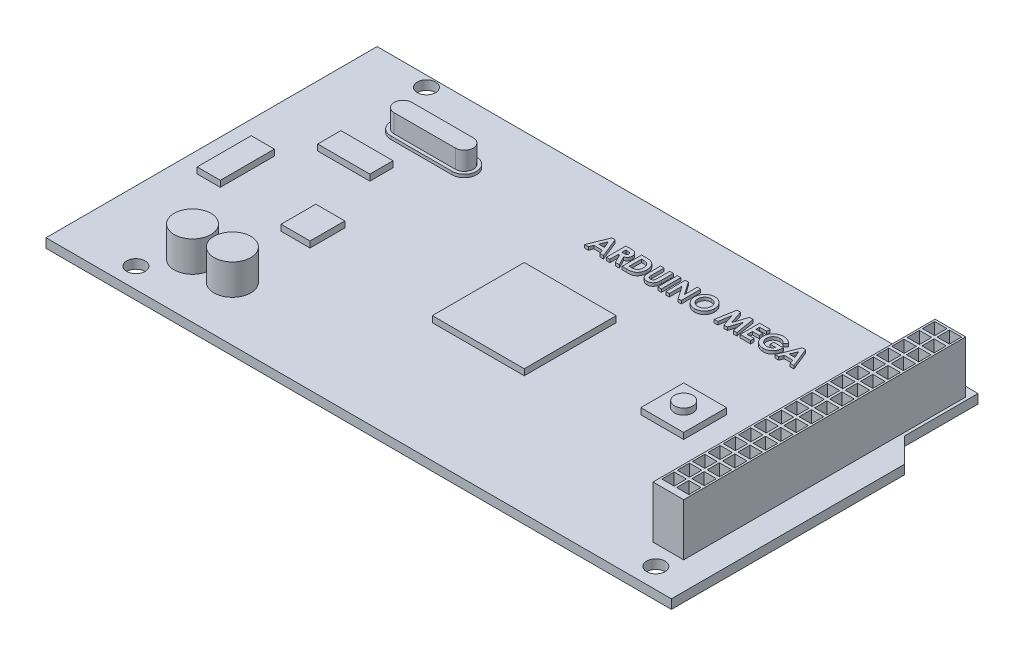
from build123d import *

# Parameters (mm, degrees)
SKETCH1_W            = 102
SKETCH1_H            = 54
BOSS_EXTRUDE1_DEPTH  = 1.5
CUT_EXTRUDE1_DEPTH   = 1.5
SKETCH3_W            = 5
SKETCH3_H            = 46
BOSS_EXTRUDE2_DEPTH  = 8.5
SKETCH4_W            = 2
SKETCH4_H            = 2
CUT_EXTRUDE2_DEPTH   = 5
SKETCH5_W            = 15
SKETCH5_H            = 15
BOSS_EXTRUDE3_DEPTH  = 1
SKETCH6_R            = 3
BOSS_EXTRUDE4_DEPTH  = 5
BOSS_EXTRUDE5_DEPTH  = 0.5
SKETCH8_W            = 8.498910204
SKETCH8_H            = 3.777293425
BOSS_EXTRUDE6_DEPTH  = 1
SKETCH9_W            = 4.72161678
SKETCH9_H            = 5.665940136
BOSS_EXTRUDE7_DEPTH  = 1
SKETCH10_R           = 1.5
CUT_EXTRUDE3_DEPTH   = 11
SKETCH11_R           = 1.5
CUT_EXTRUDE4_DEPTH   = 11
SKETCH12_R           = 1.5
CUT_EXTRUDE5_DEPTH   = 11
SKETCH13_R           = 1.5
CUT_EXTRUDE6_DEPTH   = 11
SKETCH14_W           = 7
SKETCH14_H           = 7
BOSS_EXTRUDE8_DEPTH  = 1
SKETCH15_R           = 1.5
BOSS_EXTRUDE9_DEPTH  = 1
SKETCH16_W           = 3.779662731
SKETCH16_H           = 8.81921304
BOSS_EXTRUDE10_DEPTH = 1
SKETCH17_W           = 0.569871795
SKETCH17_H           = 3.175
BOSS_EXTRUDE11_DEPTH = 0.5
BOSS_EXTRUDE12_DEPTH = 3


with BuildPart() as part:
    # Sketch1 → Boss-Extrude1 (new body)
    with BuildSketch(Plane(origin=(0, 0, 0), x_dir=(1, 0, 0), z_dir=(0, 1, 0))):
        Rectangle(SKETCH1_W, SKETCH1_H)
    extrude(amount=BOSS_EXTRUDE1_DEPTH)

    # Sketch2 → Cut-Extrude1 (cut)
    with BuildSketch(Plane(origin=(0, 1.5, 0), x_dir=(1, 0, 0), z_dir=(0, 1, 0))):
        Polygon((47, 27), (47, 15), (51, 11), (51, 27), align=None)
    extrude(amount=-CUT_EXTRUDE1_DEPTH, mode=Mode.SUBTRACT)

    # Sketch3 → Boss-Extrude2 (add)
    with BuildSketch(Plane(origin=(0, 1.5, 0), x_dir=(1, 0, 0), z_dir=(0, 1, 0))):
        with Locations((44, 2.5)):
            Rectangle(SKETCH3_W, SKETCH3_H)
    extrude(amount=BOSS_EXTRUDE2_DEPTH)

    # Sketch4 → Cut-Extrude2 (cut)
    with BuildSketch(Plane(origin=(0, 10, 0), x_dir=(1, 0, 0), z_dir=(0, 1, 0))):
        with Locations((45.197057876, 24.138037012)):
            Rectangle(SKETCH4_W, SKETCH4_H)
        with Locations((42.802942124, 24.138037012)):
            Rectangle(SKETCH4_W, SKETCH4_H)
        with Locations((42.802942124, 21.638037012)):
            Rectangle(SKETCH4_W, SKETCH4_H)
        with Locations((45.197057876, 21.638037012)):
            Rectangle(SKETCH4_W, SKETCH4_H)
        with Locations((42.802942124, 19.138037012)):
            Rectangle(SKETCH4_W, SKETCH4_H)
        with Locations((45.197057876, 19.138037012)):
            Rectangle(SKETCH4_W, SKETCH4_H)
        with Locations((42.802942124, 16.638037012)):
            Rectangle(SKETCH4_W, SKETCH4_H)
        with Locations((45.197057876, 16.638037012)):
            Rectangle(SKETCH4_W, SKETCH4_H)
        with Locations((42.802942124, 14.138037012)):
            Rectangle(SKETCH4_W, SKETCH4_H)
        with Locations((45.197057876, 14.138037012)):
            Rectangle(SKETCH4_W, SKETCH4_H)
        with Locations((42.802942124, 11.638037012)):
            Rectangle(SKETCH4_W, SKETCH4_H)
        with Locations((45.197057876, 11.638037012)):
            Rectangle(SKETCH4_W, SKETCH4_H)
        with Locations((42.802942124, 9.138037012)):
            Rectangle(SKETCH4_W, SKETCH4_H)
        with Locations((45.197057876, 9.138037012)):
            Rectangle(SKETCH4_W, SKETCH4_H)
        with Locations((42.802942124, 6.638037012)):
            Rectangle(SKETCH4_W, SKETCH4_H)
        with Locations((45.197057876, 6.638037012)):
            Rectangle(SKETCH4_W, SKETCH4_H)
        with Locations((42.802942124, 4.138037012)):
            Rectangle(SKETCH4_W, SKETCH4_H)
        with Locations((45.197057876, 4.138037012)):
            Rectangle(SKETCH4_W, SKETCH4_H)
        with Locations((42.802942124, 1.638037012)):
            Rectangle(SKETCH4_W, SKETCH4_H)
        with Locations((45.197057876, 1.638037012)):
            Rectangle(SKETCH4_W, SKETCH4_H)
        with Locations((42.802942124, -0.861962988)):
            Rectangle(SKETCH4_W, SKETCH4_H)
        with Locations((45.197057876, -0.861962988)):
            Rectangle(SKETCH4_W, SKETCH4_H)
        with Locations((42.802942124, -3.361962988)):
            Rectangle(SKETCH4_W, SKETCH4_H)
        with Locations((45.197057876, -3.361962988)):
            Rectangle(SKETCH4_W, SKETCH4_H)
        with Locations((42.802942124, -5.861962988)):
            Rectangle(SKETCH4_W, SKETCH4_H)
        with Locations((45.197057876, -5.861962988)):
            Rectangle(SKETCH4_W, SKETCH4_H)
        with Locations((42.802942124, -8.361962988)):
            Rectangle(SKETCH4_W, SKETCH4_H)
        with Locations((45.197057876, -8.361962988)):
            Rectangle(SKETCH4_W, SKETCH4_H)
        with Locations((42.802942124, -10.861962988)):
            Rectangle(SKETCH4_W, SKETCH4_H)
        with Locations((45.197057876, -10.861962988)):
            Rectangle(SKETCH4_W, SKETCH4_H)
        with Locations((42.802942124, -13.361962988)):
            Rectangle(SKETCH4_W, SKETCH4_H)
        with Locations((45.197057876, -13.361962988)):
            Rectangle(SKETCH4_W, SKETCH4_H)
        with Locations((42.802942124, -15.861962988)):
            Rectangle(SKETCH4_W, SKETCH4_H)
        with Locations((45.197057876, -15.861962988)):
            Rectangle(SKETCH4_W, SKETCH4_H)
        with Locations((42.802942124, -18.361962988)):
            Rectangle(SKETCH4_W, SKETCH4_H)
        with Locations((45.197057876, -18.361962988)):
            Rectangle(SKETCH4_W, SKETCH4_H)
    extrude(amount=-CUT_EXTRUDE2_DEPTH, mode=Mode.SUBTRACT)

    # Sketch5 → Boss-Extrude3 (add)
    with BuildSketch(Plane(origin=(0, 1.5, 0), x_dir=(1, 0, 0), z_dir=(0, 1, 0))):
        Rectangle(SKETCH5_W, SKETCH5_H)
    extrude(amount=BOSS_EXTRUDE3_DEPTH)

    # Sketch6 → Boss-Extrude4 (add)
    with BuildSketch(Plane(origin=(0, 1.5, 0), x_dir=(1, 0, 0), z_dir=(0, 1, 0))):
        with Locations((-36, -18.099530991)):
            Circle(SKETCH6_R)
        with Locations((-29.5, -18.099530991)):
            Circle(SKETCH6_R)
    extrude(amount=BOSS_EXTRUDE4_DEPTH)

    # Sketch7 → Boss-Extrude5 (add)
    with BuildSketch(Plane(origin=(0, 1.5, 0), x_dir=(1, 0, 0), z_dir=(0, 1, 0))):
        with BuildLine():
            Line((-36.773349322, 19), (-26.773349322, 19))
            ThreePointArc((-26.773349322, 19), (-24.773349322, 17), (-26.773349322, 15))
            Line((-26.773349322, 15), (-36.773349322, 15))
            ThreePointArc((-36.773349322, 15), (-38.773349322, 17), (-36.773349322, 19))
        make_face()
    extrude(amount=BOSS_EXTRUDE5_DEPTH)

    # Sketch8 → Boss-Extrude6 (add)
    with BuildSketch(Plane(origin=(0, 1.5, 0), x_dir=(1, 0, 0), z_dir=(0, 1, 0))):
        with Locations((-36.828610886, 9.285846335)):
            Rectangle(SKETCH8_W, SKETCH8_H)
    extrude(amount=BOSS_EXTRUDE6_DEPTH)

    # Sketch9 → Boss-Extrude7 (add)
    with BuildSketch(Plane(origin=(0, 1.5, 0), x_dir=(1, 0, 0), z_dir=(0, 1, 0))):
        with Locations((-30.37573462, -4.092067876)):
            Rectangle(SKETCH9_W, SKETCH9_H)
    extrude(amount=BOSS_EXTRUDE7_DEPTH)

    # Sketch10 → Cut-Extrude3 (cut)
    with BuildSketch(Plane(origin=(0, 1.5, 0), x_dir=(1, 0, 0), z_dir=(0, 1, 0))):
        with Locations((45.143571623, -23.68473148)):
            Circle(SKETCH10_R)
    extrude(amount=-CUT_EXTRUDE3_DEPTH, mode=Mode.SUBTRACT)

    # Sketch11 → Cut-Extrude4 (cut)
    with BuildSketch(Plane(origin=(0, 1.5, 0), x_dir=(1, 0, 0), z_dir=(0, 1, 0))):
        with Locations((39.547226462, 25.26724781)):
            Circle(SKETCH11_R)
    extrude(amount=-CUT_EXTRUDE4_DEPTH, mode=Mode.SUBTRACT)

    # Sketch12 → Cut-Extrude5 (cut)
    with BuildSketch(Plane(origin=(0, 1.5, 0), x_dir=(1, 0, 0), z_dir=(0, 1, 0))):
        with Locations((-41.217820337, 25.26724781)):
            Circle(SKETCH12_R)
    extrude(amount=-CUT_EXTRUDE5_DEPTH, mode=Mode.SUBTRACT)

    # Sketch13 → Cut-Extrude6 (cut)
    with BuildSketch(Plane(origin=(0, 1.5, 0), x_dir=(1, 0, 0), z_dir=(0, 1, 0))):
        with Locations((-39.661580954, -23.68473148)):
            Circle(SKETCH13_R)
    extrude(amount=-CUT_EXTRUDE6_DEPTH, mode=Mode.SUBTRACT)

    # Sketch14 → Boss-Extrude8 (add)
    with BuildSketch(Plane(origin=(0, 1.5, 0), x_dir=(1, 0, 0), z_dir=(0, 1, 0))):
        with Locations((26, 0)):
            Rectangle(SKETCH14_W, SKETCH14_H)
    extrude(amount=BOSS_EXTRUDE8_DEPTH)

    # Sketch15 → Boss-Extrude9 (add)
    with BuildSketch(Plane(origin=(0, 2.5, 0), x_dir=(1, 0, 0), z_dir=(0, 1, 0))):
        with Locations((26, 0)):
            Circle(SKETCH15_R)
    extrude(amount=BOSS_EXTRUDE9_DEPTH)

    # Sketch16 → Boss-Extrude10 (add)
    with BuildSketch(Plane(origin=(0, 1.5, 0), x_dir=(1, 0, 0), z_dir=(0, 1, 0))):
        with Locations((-45.788642677, -1.263618567)):
            Rectangle(SKETCH16_W, SKETCH16_H)
    extrude(amount=BOSS_EXTRUDE10_DEPTH)

    # Sketch17 → Boss-Extrude11 (add)
    with BuildSketch(Plane(origin=(0, 1.5, 0), x_dir=(1, 0, 0), z_dir=(0, 1, 0))):
        Polygon((-4.331151445, 18.623765443), (-3.802620796, 18.623765443), (-2.520409257, 15.448765443), (-3.129078128, 15.448765443), (-3.375852967, 16.100047494), (-4.759191309, 16.100047494), (-5.005966148, 15.448765443), (-5.613999001, 15.448765443), align=None)
        Polygon((-4.067204129, 17.772137839), (-4.542945315, 16.669919289), (-3.591462943, 16.669919289), align=None, mode=Mode.SUBTRACT)
        with BuildLine():
            Line((-2.052300283, 18.623765443), (-1.388297879, 18.623765443))
            add(Edge.make_bspline(
                [(-1.388297879, 18.623765443), (-1.344407522, 18.623609657), (-1.259994003, 18.623310038), (-1.138274319, 18.618582835), (-1.02645805, 18.612004544), (-0.924379641, 18.601965898), (-0.832082765, 18.588655867), (-0.749474917, 18.572965542), (-0.676558513, 18.555083053), (-0.612718603, 18.532800061), (-0.555106241, 18.507665184), (-0.501403509, 18.47878475), (-0.450425647, 18.446480351), (-0.402513386, 18.40990197), (-0.357250356, 18.369707645), (-0.314551167, 18.325856916), (-0.275019198, 18.277977945), (-0.238899232, 18.226373269), (-0.205978791, 18.172086333), (-0.176884025, 18.1150426), (-0.153224113, 18.055202401), (-0.132318045, 17.993430557), (-0.117260081, 17.928844025), (-0.106787487, 17.862071568), (-0.099119864, 17.792878139), (-0.098679012, 17.745871196), (-0.098454129, 17.721892446)],
                knots=[0, 0, 0, 0, 0.000131662, 0.000253223, 0.00036538, 0.000467651, 0.000560835, 0.000645033, 0.000719848, 0.000785822, 0.000847624, 0.000908233, 0.000968574, 0.001028488, 0.00108886, 0.00115003, 0.00121192, 0.001274915, 0.001338834, 0.001402263, 0.001466749, 0.001531714, 0.00159774, 0.001665392, 0.001734437, 0.001806332, 0.001806332, 0.001806332, 0.001806332], degree=3))
            add(Edge.make_bspline(
                [(-0.098454129, 17.721892446), (-0.099038295, 17.69686414), (-0.100183737, 17.647788194), (-0.106353713, 17.575699631), (-0.117630492, 17.506730336), (-0.134710813, 17.441082244), (-0.154342424, 17.377938286), (-0.18044743, 17.318463509), (-0.20990951, 17.261792937), (-0.244900762, 17.208728199), (-0.283301951, 17.158090618), (-0.327961726, 17.111820311), (-0.37598682, 17.067430421), (-0.430076897, 17.027701382), (-0.487847618, 16.98994686), (-0.550446826, 16.955731208), (-0.617465976, 16.924194324), (-0.664583758, 16.906607179), (-0.688678488, 16.8976136)],
                knots=[0, 0, 0, 0, 7.5093e-05, 0.000147244, 0.000216881, 0.000284446, 0.00035062, 0.000415008, 0.000479022, 0.000542001, 0.000605481, 0.000669369, 0.000734656, 0.000801438, 0.000870416, 0.000941581, 0.001015277, 0.001092403, 0.001092403, 0.001092403, 0.001092403], degree=3))
            Line((-0.688678488, 16.8976136), (0.04401382, 15.448765443))
            Line((0.04401382, 15.448765443), (-0.589459738, 15.448765443))
            Line((-0.589459738, 15.448765443), (-1.289079129, 16.832739802))
            Line((-1.289079129, 16.832739802), (-1.482428488, 16.832739802))
            Line((-1.482428488, 16.832739802), (-1.482428488, 15.448765443))
            Line((-1.482428488, 15.448765443), (-2.052300283, 15.448765443))
            Line((-2.052300283, 15.448765443), (-2.052300283, 18.623765443))
        make_face()
        with BuildLine():
            Line((-1.482428488, 17.402611597), (-1.260458336, 17.402611597))
            add(Edge.make_bspline(
                [(-1.260458336, 17.402611597), (-1.23332064, 17.40291724), (-1.181357783, 17.40350248), (-1.106628369, 17.406217069), (-1.03875624, 17.412757886), (-0.977449928, 17.421021964), (-0.922400948, 17.430564035), (-0.874100315, 17.444238403), (-0.831803791, 17.458890834), (-0.796012591, 17.477100006), (-0.765433412, 17.497807783), (-0.739030249, 17.521332332), (-0.717191046, 17.548559002), (-0.699216269, 17.578747891), (-0.685233847, 17.61216601), (-0.67502775, 17.648446505), (-0.66932405, 17.688002656), (-0.66866782, 17.715301787), (-0.668325924, 17.729524658)],
                knots=[0, 0, 0, 0, 8.142e-05, 0.000155902, 0.000224253, 0.000285868, 0.000341504, 0.000391652, 0.000436319, 0.000475572, 0.000511736, 0.000546861, 0.000581229, 0.000616025, 0.000651936, 0.00068959, 0.000728807, 0.000771463, 0.000771463, 0.000771463, 0.000771463], degree=3))
            add(Edge.make_bspline(
                [(-0.668325924, 17.729524658), (-0.66897231, 17.746351351), (-0.670242017, 17.779404273), (-0.682841449, 17.82698889), (-0.702897023, 17.871031709), (-0.730387721, 17.911333733), (-0.765008682, 17.94666527), (-0.804738967, 17.977810301), (-0.85043605, 18.002437461), (-0.89274811, 18.018681273), (-0.931242194, 18.028400114), (-0.965981891, 18.035642508), (-1.006210669, 18.0407754), (-1.051958899, 18.046219747), (-1.103109967, 18.04975013), (-1.159942677, 18.052326606), (-1.222293806, 18.053380768), (-1.265758464, 18.053717766), (-1.288443112, 18.053893648)],
                knots=[0, 0, 0, 0, 5.039e-05, 9.8982e-05, 0.000146513, 0.000195026, 0.000244505, 0.000294375, 0.000345896, 0.000399642, 0.000429878, 0.000464928, 0.000506034, 0.000551477, 0.000603136, 0.000659798, 0.000722141, 0.000790198, 0.000790198, 0.000790198, 0.000790198], degree=3))
            Line((-1.288443112, 18.053893648), (-1.482428488, 18.053893648))
            Line((-1.482428488, 18.053893648), (-1.482428488, 17.402611597))
        make_face(mode=Mode.SUBTRACT)
        with BuildLine():
            Line((0.512122794, 18.623765443), (1.230186696, 18.623765443))
            add(Edge.make_bspline(
                [(1.230186696, 18.623765443), (1.286168037, 18.623374114), (1.3943806, 18.622617671), (1.551159197, 18.614094379), (1.696943342, 18.600986162), (1.83182701, 18.582953433), (1.955533668, 18.559091194), (2.067903798, 18.529160692), (2.169314542, 18.494610907), (2.260877847, 18.453956075), (2.344466338, 18.406556577), (2.423836278, 18.353757343), (2.498831826, 18.29362418), (2.570505425, 18.227317179), (2.637932114, 18.153623273), (2.702234787, 18.073763099), (2.761839024, 17.986578576), (2.818546531, 17.894160112), (2.869830926, 17.796116049), (2.914563091, 17.693280915), (2.952035498, 17.586316493), (2.982483768, 17.475108788), (3.006754554, 17.360026975), (3.023736333, 17.24083883), (3.034234639, 17.117654701), (3.035299604, 17.034166768), (3.035840743, 16.991744209)],
                knots=[0, 0, 0, 0, 0.000167928, 0.000324607, 0.000470866, 0.000606957, 0.000732689, 0.000848551, 0.000955557, 0.00105378, 0.001148607, 0.00124351, 0.001339462, 0.001436671, 0.001536144, 0.001638851, 0.001743999, 0.001852751, 0.001963983, 0.002075642, 0.002188891, 0.002303691, 0.00242132, 0.002541489, 0.002664661, 0.002791905, 0.002791905, 0.002791905, 0.002791905], degree=3))
            add(Edge.make_bspline(
                [(3.035840743, 16.991744209), (3.034423749, 16.931883217), (3.031634315, 16.814043349), (3.008137679, 16.641114701), (2.970135662, 16.475345345), (2.916701376, 16.318031992), (2.850457164, 16.17057554), (2.771321035, 16.035576324), (2.68045331, 15.91375895), (2.578912601, 15.805729968), (2.468968744, 15.712877595), (2.354714906, 15.633356332), (2.235038046, 15.57064718), (2.129586008, 15.530880201), (2.038145935, 15.50614858), (1.95786254, 15.491531954), (1.866668795, 15.478127626), (1.763714397, 15.46776905), (1.649450985, 15.458531746), (1.523423104, 15.453512554), (1.386038796, 15.449342351), (1.290612404, 15.448962784), (1.240998996, 15.448765443)],
                knots=[0, 0, 0, 0, 0.000179519, 0.000353394, 0.000522485, 0.00068902, 0.000850985, 0.001006643, 0.001157506, 0.001305986, 0.001450375, 0.001588509, 0.001722787, 0.001854621, 0.001925744, 0.002006699, 0.002099254, 0.002202222, 0.002317051, 0.002443112, 0.002580545, 0.002729379, 0.002729379, 0.002729379, 0.002729379], degree=3))
            Line((1.240998996, 15.448765443), (0.512122794, 15.448765443))
            Line((0.512122794, 15.448765443), (0.512122794, 18.623765443))
        make_face()
        with BuildLine():
            Line((1.081994589, 18.053893648), (1.081994589, 16.018637238))
            Line((1.081994589, 16.018637238), (1.379650839, 16.018637238))
            add(Edge.make_bspline(
                [(1.379650839, 16.018637238), (1.415067361, 16.018702135), (1.483185124, 16.018826955), (1.581531755, 16.024772237), (1.672477451, 16.03073966), (1.755771862, 16.042066029), (1.832021177, 16.054682807), (1.900177931, 16.072240781), (1.961647131, 16.090683946), (2.015677942, 16.11416438), (2.065165763, 16.140593171), (2.110985833, 16.171557564), (2.155215028, 16.205942355), (2.197026449, 16.244758849), (2.236578342, 16.287493043), (2.273636693, 16.334365127), (2.308696133, 16.385232094), (2.340856752, 16.440362888), (2.370245298, 16.499175318), (2.396316231, 16.561099698), (2.417932882, 16.626651726), (2.435899319, 16.695217755), (2.448738375, 16.767394731), (2.459360245, 16.842648049), (2.464836129, 16.921275856), (2.46558766, 16.974776844), (2.465968948, 17.001920491)],
                knots=[0, 0, 0, 0, 0.000106223, 0.000204301, 0.000295521, 0.000379537, 0.000456393, 0.000527197, 0.00059056, 0.000648685, 0.000703608, 0.000758644, 0.000814371, 0.000871531, 0.00092959, 0.00098889, 0.001050637, 0.001114777, 0.001180197, 0.001247762, 0.001316145, 0.001387105, 0.001460206, 0.001535943, 0.001615016, 0.001696449, 0.001696449, 0.001696449, 0.001696449], degree=3))
            add(Edge.make_bspline(
                [(2.465968948, 17.001920491), (2.465209551, 17.043515564), (2.463728787, 17.124622734), (2.449448618, 17.242757098), (2.426203226, 17.353998299), (2.393034291, 17.457933491), (2.351223822, 17.554854786), (2.298888272, 17.643941056), (2.238279964, 17.726688828), (2.190352567, 17.775231326), (2.166404645, 17.799486597)],
                knots=[0, 0, 0, 0, 0.000124739, 0.000243231, 0.000356373, 0.000465191, 0.000570003, 0.000672325, 0.000774597, 0.000876735, 0.000876735, 0.000876735, 0.000876735], degree=3))
            add(Edge.make_bspline(
                [(2.166404645, 17.799486597), (2.142789726, 17.820155366), (2.094558928, 17.862368988), (2.009881496, 17.912951702), (1.916571351, 17.957393574), (1.812493838, 17.992631022), (1.698654819, 18.020498298), (1.574376266, 18.039717677), (1.440323718, 18.052067847), (1.347455237, 18.053272009), (1.299512618, 18.053893648)],
                knots=[0, 0, 0, 0, 9.3976e-05, 0.000191935, 0.000294641, 0.000403659, 0.000520895, 0.000645848, 0.00078059, 0.000924381, 0.000924381, 0.000924381, 0.000924381], degree=3))
            Line((1.299512618, 18.053893648), (1.081994589, 18.053893648))
        make_face(mode=Mode.SUBTRACT)
        with BuildLine():
            Line((3.605712537, 18.623765443), (4.175584332, 18.623765443))
            Line((4.175584332, 18.623765443), (4.175584332, 16.557980186))
            add(Edge.make_bspline(
                [(4.175584332, 16.557980186), (4.175615319, 16.536563021), (4.17567517, 16.495195987), (4.178671328, 16.435847837), (4.181413019, 16.381294461), (4.186359809, 16.331595583), (4.193667912, 16.286729944), (4.200744541, 16.246409343), (4.210322058, 16.211355675), (4.224715535, 16.171455423), (4.246891158, 16.126625311), (4.283124896, 16.079902339), (4.32493553, 16.037260846), (4.375047983, 16.001767683), (4.431369948, 15.973056913), (4.493591962, 15.95178541), (4.561626313, 15.939961278), (4.608668334, 15.938156108), (4.632881007, 15.937226981)],
                knots=[0, 0, 0, 0, 6.4241e-05, 0.000124081, 0.000178236, 0.000228105, 0.000273801, 0.000314591, 0.000350849, 0.000382638, 0.000441801, 0.000499933, 0.000559298, 0.000620369, 0.000683231, 0.000748398, 0.00081689, 0.000889533, 0.000889533, 0.000889533, 0.000889533], degree=3))
            add(Edge.make_bspline(
                [(4.632881007, 15.937226981), (4.658603984, 15.937977596), (4.708759434, 15.939441169), (4.780900064, 15.953807715), (4.847738767, 15.976684178), (4.90786034, 16.00933472), (4.961204952, 16.048472116), (5.006360047, 16.093101013), (5.041996283, 16.143310422), (5.065222656, 16.189632426), (5.07826312, 16.232267796), (5.088037598, 16.270360881), (5.095203371, 16.315306952), (5.101704396, 16.366404077), (5.105611012, 16.424181525), (5.109847099, 16.488174642), (5.111399665, 16.558821286), (5.111664288, 16.60801387), (5.111802281, 16.633666284)],
                knots=[0, 0, 0, 0, 7.7087e-05, 0.000150306, 0.000219702, 0.00028828, 0.000354682, 0.000417645, 0.000477828, 0.0005387, 0.00057209, 0.000611425, 0.000656596, 0.000708504, 0.000765919, 0.00083027, 0.000900894, 0.000977854, 0.000977854, 0.000977854, 0.000977854], degree=3))
            Line((5.111802281, 16.633666284), (5.111802281, 18.623765443))
            Line((5.111802281, 18.623765443), (5.681674076, 18.623765443))
            Line((5.681674076, 18.623765443), (5.681674076, 16.729704946))
            add(Edge.make_bspline(
                [(5.681674076, 16.729704946), (5.681594939, 16.691331371), (5.681442766, 16.617542728), (5.67910585, 16.511503256), (5.674130978, 16.414653208), (5.66995266, 16.326964284), (5.661866183, 16.248554617), (5.653441971, 16.179089373), (5.642704588, 16.118814723), (5.626728008, 16.050199359), (5.599157161, 15.97119128), (5.554709341, 15.880216902), (5.49828571, 15.791147476), (5.431595798, 15.704962825), (5.356296787, 15.624900063), (5.274058217, 15.554615321), (5.186186655, 15.495162008), (5.091763905, 15.447993829), (4.990870327, 15.411206206), (4.882507654, 15.386486776), (4.766749781, 15.369786019), (4.68679363, 15.368181706), (4.64560136, 15.367355186)],
                knots=[0, 0, 0, 0, 0.000115121, 0.000221366, 0.000318143, 0.000406061, 0.000484663, 0.000554558, 0.00061594, 0.000668237, 0.000765788, 0.0008662, 0.000971372, 0.001081543, 0.001192671, 0.001300497, 0.001405455, 0.001510128, 0.00161636, 0.001726816, 0.001843029, 0.001966521, 0.001966521, 0.001966521, 0.001966521], degree=3))
            add(Edge.make_bspline(
                [(4.64560136, 15.367355186), (4.618232396, 15.36781618), (4.564233991, 15.368725712), (4.484819865, 15.376745407), (4.408050512, 15.388563421), (4.334070181, 15.405804688), (4.2626221, 15.428077183), (4.193725252, 15.455493074), (4.127635674, 15.487899438), (4.064723194, 15.524998207), (4.005065231, 15.565114139), (3.950540932, 15.609584338), (3.899273988, 15.655120065), (3.852745481, 15.703637657), (3.810605938, 15.754627762), (3.772942147, 15.80820594), (3.739810064, 15.864367433), (3.710376269, 15.924124547), (3.685183813, 15.990514521), (3.663945627, 16.065898874), (3.645391447, 16.15145918), (3.631603076, 16.247388202), (3.619102457, 16.353369769), (3.611190255, 16.469679979), (3.607051026, 16.596322169), (3.606169974, 16.684120574), (3.605712537, 16.729704946)],
                knots=[0, 0, 0, 0, 8.2086e-05, 0.000161953, 0.000239226, 0.000314976, 0.000389608, 0.000463542, 0.000537213, 0.000610189, 0.000682516, 0.000752643, 0.000821097, 0.00088812, 0.000954082, 0.001019369, 0.00108438, 0.001149519, 0.001218973, 0.001297076, 0.001384276, 0.001481422, 0.00158769, 0.001704375, 0.00183102, 0.001967778, 0.001967778, 0.001967778, 0.001967778], degree=3))
            Line((3.605712537, 16.729704946), (3.605712537, 18.623765443))
        make_face()
        with Locations((6.617892024, 17.036265443)):
            Rectangle(SKETCH17_W, SKETCH17_H)
        Polygon((7.63552023, 18.623765443), (8.148786456, 18.623765443), (9.589366384, 16.534447534), (9.589366384, 18.623765443), (10.159238179, 18.623765443), (10.159238179, 15.448765443), (9.642155847, 15.448765443), (8.205392025, 17.531723175), (8.205392025, 15.448765443), (7.63552023, 15.448765443), align=None)
        with BuildLine():
            add(Edge.make_bspline(
                [(12.384027842, 18.705175699), (12.439229108, 18.70374644), (12.54820891, 18.700924757), (12.708478873, 18.677403834), (12.862928615, 18.639079861), (13.011488296, 18.585806766), (13.153785939, 18.516141644), (13.290323476, 18.432059546), (13.420611835, 18.331973473), (13.543315926, 18.218218269), (13.656716637, 18.094514451), (13.754978418, 17.961325298), (13.838772461, 17.822101875), (13.908221188, 17.676471129), (13.961119319, 17.523424497), (13.998240127, 17.363742314), (14.022088406, 17.19747001), (14.024831325, 17.084261234), (14.026225358, 17.026725178)],
                knots=[0, 0, 0, 0, 0.000165541, 0.000326815, 0.000484774, 0.000642302, 0.00079932, 0.000959238, 0.001122574, 0.001291359, 0.001460652, 0.001625256, 0.001787016, 0.001947474, 0.002108388, 0.00227176, 0.002438702, 0.002611232, 0.002611232, 0.002611232, 0.002611232], degree=3))
            add(Edge.make_bspline(
                [(14.026225358, 17.026725178), (14.024740773, 16.969837421), (14.021815352, 16.85773827), (13.999213718, 16.692998231), (13.961467792, 16.535026578), (13.909466853, 16.383465738), (13.841277664, 16.239049821), (13.759117697, 16.100856751), (13.660818906, 15.970168992), (13.549966634, 15.847056677), (13.427927903, 15.735305835), (13.298669514, 15.636825598), (13.162788301, 15.553377161), (13.020483152, 15.484998749), (12.8714489, 15.431932781), (12.716053678, 15.394490885), (12.554307102, 15.371736688), (12.444311586, 15.368830375), (12.388479965, 15.367355186)],
                knots=[0, 0, 0, 0, 0.000170624, 0.000336219, 0.000497735, 0.000657239, 0.000816004, 0.000976019, 0.001138712, 0.001305782, 0.001472338, 0.001634398, 0.001792566, 0.00194988, 0.002107193, 0.002266236, 0.002428681, 0.002596127, 0.002596127, 0.002596127, 0.002596127], degree=3))
            add(Edge.make_bspline(
                [(12.388479965, 15.367355186), (12.330086785, 15.368678504), (12.215352167, 15.371278641), (12.047437539, 15.39600476), (11.886560817, 15.433250933), (11.734073458, 15.488838848), (11.588422507, 15.558328417), (11.450678106, 15.643908986), (11.320886545, 15.745439128), (11.19979233, 15.860318618), (11.090080678, 15.986021977), (10.993238625, 16.118816429), (10.911550206, 16.25768754), (10.84501243, 16.402700306), (10.79255672, 16.552953507), (10.755555178, 16.709362229), (10.733697483, 16.871551346), (10.730652833, 16.981713437), (10.729109973, 17.037537478)],
                knots=[0, 0, 0, 0, 0.000175071, 0.000343991, 0.000508129, 0.000669679, 0.000829837, 0.000991505, 0.001155115, 0.001323375, 0.001491502, 0.001654978, 0.001815764, 0.001973993, 0.002132895, 0.002292408, 0.002455397, 0.002622844, 0.002622844, 0.002622844, 0.002622844], degree=3))
            add(Edge.make_bspline(
                [(10.729109973, 17.037537478), (10.729594212, 17.075092971), (10.730556557, 17.149728417), (10.742149016, 17.260334339), (10.758838825, 17.368781381), (10.78352226, 17.474637165), (10.813506324, 17.578648453), (10.852354916, 17.679847082), (10.896575126, 17.779314132), (10.948242278, 17.875874773), (11.005691155, 17.968640567), (11.068372996, 18.05717392), (11.136445411, 18.140404335), (11.209689118, 18.218878768), (11.288356524, 18.292081401), (11.371412841, 18.361048519), (11.460468878, 18.42394811), (11.553575477, 18.482316308), (11.650207725, 18.535097657), (11.749972241, 18.580023563), (11.850813679, 18.619256592), (11.954079144, 18.650221032), (12.058661964, 18.675441245), (12.165679394, 18.692119805), (12.274164592, 18.703711943), (12.347319849, 18.704686623), (12.384027842, 18.705175699)],
                knots=[0, 0, 0, 0, 0.00011262, 0.000223814, 0.000333292, 0.000441602, 0.000549675, 0.000657762, 0.000766512, 0.000876056, 0.000986016, 0.001093666, 0.001201246, 0.001308342, 0.001415439, 0.001523422, 0.001631959, 0.001742255, 0.001852962, 0.001961973, 0.002070287, 0.002177323, 0.002285158, 0.002392752, 0.002502047, 0.002612124, 0.002612124, 0.002612124, 0.002612124], degree=3))
        make_face()
        with BuildLine():
            add(Edge.make_bspline(
                [(12.375123595, 18.135303904), (12.33797315, 18.134307075), (12.264653039, 18.132339731), (12.157105787, 18.117351237), (12.053856628, 18.093412907), (11.955477912, 18.05873853), (11.861543256, 18.014606848), (11.771886145, 17.961172062), (11.687748143, 17.896597413), (11.608007352, 17.824349624), (11.535974669, 17.743848984), (11.472331521, 17.657578857), (11.419072457, 17.565683314), (11.374467657, 17.469016042), (11.340890129, 17.366490043), (11.316973862, 17.258908415), (11.301859674, 17.146085788), (11.299954512, 17.069174751), (11.298981768, 17.029905267)],
                knots=[0, 0, 0, 0, 0.000111419, 0.000219897, 0.00032511, 0.000428903, 0.000532185, 0.000636026, 0.000741351, 0.00084985, 0.000958393, 0.001064868, 0.001170898, 0.001276489, 0.001383689, 0.00149386, 0.001606751, 0.001724524, 0.001724524, 0.001724524, 0.001724524], degree=3))
            add(Edge.make_bspline(
                [(11.298981768, 17.029905267), (11.300271478, 16.986385844), (11.302799096, 16.901094987), (11.32058372, 16.776674983), (11.351011441, 16.659172638), (11.394948479, 16.549162638), (11.449441933, 16.445423404), (11.517114155, 16.349226409), (11.596869174, 16.25999567), (11.658311795, 16.207899048), (11.689496592, 16.181457751)],
                knots=[0, 0, 0, 0, 0.000130539, 0.000255834, 0.000376163, 0.000493797, 0.00061045, 0.000726904, 0.0008458, 0.000968339, 0.000968339, 0.000968339, 0.000968339], degree=3))
            add(Edge.make_bspline(
                [(11.689496592, 16.181457751), (11.715042895, 16.161923935), (11.765559937, 16.123296405), (11.846196136, 16.073787302), (11.929235543, 16.031353061), (12.015304794, 15.997066696), (12.104222115, 15.970097618), (12.195975314, 15.951211616), (12.290434384, 15.939359017), (12.354312034, 15.937942406), (12.386571912, 15.937226981)],
                knots=[0, 0, 0, 0, 9.6423e-05, 0.000190674, 0.000283402, 0.000375879, 0.000468233, 0.000561786, 0.00065661, 0.00075336, 0.00075336, 0.00075336, 0.00075336], degree=3))
            add(Edge.make_bspline(
                [(12.386571912, 15.937226981), (12.423083555, 15.938232263), (12.494921358, 15.940210187), (12.60046656, 15.955014165), (12.701582068, 15.98006784), (12.798895617, 16.014438042), (12.892126598, 16.059123835), (12.980819366, 16.114216), (13.065129424, 16.179038076), (13.144768626, 16.252234636), (13.217562622, 16.333052393), (13.28107296, 16.419782676), (13.336025396, 16.510514556), (13.379702638, 16.606532206), (13.414606739, 16.706929265), (13.438235161, 16.812150368), (13.453477029, 16.921761756), (13.455382728, 16.996356178), (13.456353563, 17.03435739)],
                knots=[0, 0, 0, 0, 0.000109513, 0.000215471, 0.000318978, 0.000421572, 0.000524552, 0.000628511, 0.000734222, 0.00084315, 0.000952591, 0.001059956, 0.001165215, 0.001270227, 0.001375823, 0.001483513, 0.001593251, 0.001707212, 0.001707212, 0.001707212, 0.001707212], degree=3))
            add(Edge.make_bspline(
                [(13.456353563, 17.03435739), (13.455349137, 17.072140084), (13.453372078, 17.146509555), (13.438542044, 17.255839132), (13.413647253, 17.360595716), (13.379173841, 17.460950383), (13.33515312, 17.557001521), (13.280717032, 17.648411354), (13.216056588, 17.735091514), (13.142659942, 17.816451308), (13.062772205, 17.891215746), (12.977004737, 17.956097688), (12.887757407, 18.012478033), (12.792982448, 18.056644118), (12.694618875, 18.091831145), (12.592066468, 18.117743376), (12.484936804, 18.132234436), (12.412054279, 18.134271628), (12.375123595, 18.135303904)],
                knots=[0, 0, 0, 0, 0.000113325, 0.000223064, 0.000330279, 0.000435876, 0.000540888, 0.000646693, 0.000754435, 0.000864775, 0.000975033, 0.001082142, 0.001186976, 0.001291105, 0.001395111, 0.001500005, 0.001607853, 0.001718637, 0.001718637, 0.001718637, 0.001718637], degree=3))
        make_face(mode=Mode.SUBTRACT)
        Polygon((16.068477962, 18.623765443), (16.659974356, 18.623765443), (17.384398435, 16.409152061), (18.113910654, 18.623765443), (18.69968289, 18.623765443), (19.236481768, 15.448765443), (18.659613779, 15.448765443), (18.320616384, 17.454129025), (17.660430086, 15.448765443), (17.104550679, 15.448765443), (16.448180486, 17.454129025), (16.109819108, 15.448765443), (15.532315102, 15.448765443), align=None)
        Polygon((19.765648435, 18.623765443), (21.47526382, 18.623765443), (21.47526382, 18.053893648), (20.33552023, 18.053893648), (20.33552023, 17.443316725), (21.47526382, 17.443316725), (21.47526382, 16.87344493), (20.33552023, 16.87344493), (20.33552023, 16.018637238), (21.47526382, 16.018637238), (21.47526382, 15.448765443), (19.765648435, 15.448765443), align=None)
        with BuildLine():
            Line((24.954916263, 18.118767446), (24.523696312, 17.705992005))
            add(Edge.make_bspline(
                [(24.523696312, 17.705992005), (24.489555875, 17.740173348), (24.422566704, 17.807242784), (24.313014293, 17.894538266), (24.199551244, 17.968756682), (24.081804103, 18.029784256), (23.95960885, 18.077122548), (23.833206626, 18.110985142), (23.702391792, 18.131069621), (23.613835989, 18.13388138), (23.569033852, 18.135303904)],
                knots=[0, 0, 0, 0, 0.000144839, 0.000284198, 0.000419327, 0.000551032, 0.00068131, 0.000811675, 0.000942912, 0.001077294, 0.001077294, 0.001077294, 0.001077294], degree=3))
            add(Edge.make_bspline(
                [(23.569033852, 18.135303904), (23.530191768, 18.134307148), (23.453921932, 18.132349929), (23.341850754, 18.117486945), (23.234759878, 18.092658997), (23.132143363, 18.058264021), (23.034627718, 18.013505287), (22.94164792, 17.959073592), (22.853776167, 17.894552531), (22.771704385, 17.821165198), (22.696977764, 17.741041047), (22.631737478, 17.655279873), (22.57616677, 17.565480192), (22.530420744, 17.471182575), (22.495612993, 17.37253175), (22.470764813, 17.269599333), (22.454992398, 17.16268446), (22.453130147, 17.089746026), (22.452186896, 17.052801901)],
                knots=[0, 0, 0, 0, 0.000116502, 0.000228763, 0.000338455, 0.000445857, 0.000552869, 0.000659769, 0.000768536, 0.000879349, 0.000989608, 0.001096716, 0.001202091, 0.00130592, 0.001410525, 0.001515267, 0.001623203, 0.001733987, 0.001733987, 0.001733987, 0.001733987], degree=3))
            add(Edge.make_bspline(
                [(22.452186896, 17.052801901), (22.453066716, 17.01457909), (22.45480008, 16.939274921), (22.471451004, 16.828762815), (22.497104619, 16.722442205), (22.534654671, 16.621101966), (22.580867413, 16.523353878), (22.639472783, 16.431091415), (22.70781251, 16.342905627), (22.78576448, 16.26033188), (22.870556092, 16.184218758), (22.962388167, 16.118561619), (23.05846661, 16.061913681), (23.160342131, 16.017050346), (23.266246473, 15.981030002), (23.377253811, 15.955632568), (23.493114181, 15.940051331), (23.572164667, 15.938177803), (23.61228305, 15.937226981)],
                knots=[0, 0, 0, 0, 0.000114596, 0.00022577, 0.000334522, 0.000442167, 0.000549413, 0.000658292, 0.000769355, 0.000883644, 0.000998524, 0.001110611, 0.001221769, 0.00133252, 0.001443945, 0.001556879, 0.001673636, 0.001793951, 0.001793951, 0.001793951, 0.001793951], degree=3))
            add(Edge.make_bspline(
                [(23.61228305, 15.937226981), (23.638378573, 15.937462437), (23.68960989, 15.937924688), (23.764757502, 15.945428327), (23.836730865, 15.956155651), (23.905808711, 15.970357354), (23.97129354, 15.990455312), (24.034092034, 16.013957399), (24.093836249, 16.041694549), (24.150202258, 16.074623743), (24.204028951, 16.111533345), (24.2548125, 16.153765778), (24.303443708, 16.200368857), (24.349354325, 16.251911903), (24.3917673, 16.308855774), (24.432041439, 16.370154049), (24.469715609, 16.436415077), (24.491976282, 16.483205258), (24.503343747, 16.507098776)],
                knots=[0, 0, 0, 0, 7.8253e-05, 0.000153629, 0.000226308, 0.000296538, 0.000364951, 0.000431575, 0.000497586, 0.000562275, 0.000627199, 0.000693161, 0.000760185, 0.000829113, 0.000899965, 0.000972997, 0.001049045, 0.001128405, 0.001128405, 0.001128405, 0.001128405], degree=3))
            Line((24.503343747, 16.507098776), (23.591930486, 16.507098776))
            Line((23.591930486, 16.507098776), (23.591930486, 17.076970571))
            Line((23.591930486, 17.076970571), (25.174978363, 17.076970571))
            Line((25.174978363, 17.076970571), (25.179430486, 16.941498816))
            add(Edge.make_bspline(
                [(25.179430486, 16.941498816), (25.178858421, 16.906706232), (25.177715313, 16.837183155), (25.1672685, 16.733675136), (25.149963513, 16.631539937), (25.126305939, 16.530880139), (25.096657015, 16.431201969), (25.058845355, 16.33345993), (25.014568133, 16.236991168), (24.964958646, 16.142205599), (24.909211858, 16.051256268), (24.849192254, 15.965139258), (24.785755456, 15.884003619), (24.717521739, 15.808979773), (24.645553615, 15.739437487), (24.569709413, 15.675644298), (24.489720877, 15.617546229), (24.406011737, 15.564652485), (24.31810519, 15.518294239), (24.226484546, 15.477968715), (24.131288139, 15.443721099), (24.032270194, 15.415645504), (23.929625554, 15.393982949), (23.823352021, 15.379128906), (23.713391227, 15.369035417), (23.638807146, 15.367922034), (23.600834733, 15.367355186)],
                knots=[0, 0, 0, 0, 0.000104355, 0.000208524, 0.000311726, 0.000414935, 0.00051856, 0.000623448, 0.000729039, 0.000836864, 0.000944198, 0.001048825, 0.001151634, 0.001252944, 0.001352801, 0.001451662, 0.001550001, 0.001649173, 0.001748467, 0.001847853, 0.001949249, 0.002051727, 0.002156384, 0.00226369, 0.002373501, 0.002487392, 0.002487392, 0.002487392, 0.002487392], degree=3))
            add(Edge.make_bspline(
                [(23.600834733, 15.367355186), (23.560320743, 15.367914959), (23.48000993, 15.369024596), (23.361259629, 15.3794171), (23.245954349, 15.396569258), (23.134065329, 15.420307257), (23.025332786, 15.449851094), (22.919943538, 15.486935597), (22.818113135, 15.531048787), (22.719536644, 15.581022529), (22.625473979, 15.637697105), (22.536135949, 15.70007872), (22.452010178, 15.768568646), (22.372234958, 15.842020348), (22.298674146, 15.922239274), (22.228586419, 16.006625141), (22.165367286, 16.098272886), (22.106298513, 16.194211261), (22.053821343, 16.294400064), (22.007929303, 16.396986251), (21.968792598, 16.501375846), (21.93793236, 16.608054925), (21.912876737, 16.716279629), (21.894948968, 16.826520604), (21.884824319, 16.93876405), (21.883155221, 17.01419746), (21.882315102, 17.052165884)],
                knots=[0, 0, 0, 0, 0.000121521, 0.000240891, 0.000357284, 0.000471047, 0.00058384, 0.000695077, 0.0008059, 0.000916548, 0.001026388, 0.001135078, 0.001243151, 0.001351612, 0.001460073, 0.001569442, 0.001680425, 0.001793759, 0.001907272, 0.002019444, 0.002130732, 0.002241425, 0.002352357, 0.00246382, 0.00257622, 0.002690131, 0.002690131, 0.002690131, 0.002690131], degree=3))
            add(Edge.make_bspline(
                [(21.882315102, 17.052165884), (21.8834402, 17.103962926), (21.885661937, 17.206246729), (21.906238591, 17.356911419), (21.938314528, 17.502664473), (21.984346727, 17.642975069), (22.043416909, 17.778036486), (22.114688291, 17.908165787), (22.199709042, 18.033224657), (22.265520943, 18.110653466), (22.298906648, 18.14993231)],
                knots=[0, 0, 0, 0, 0.000155319, 0.000306708, 0.000455304, 0.00060253, 0.000748932, 0.000896948, 0.001047072, 0.001201639, 0.001201639, 0.001201639, 0.001201639], degree=3))
            add(Edge.make_bspline(
                [(22.298906648, 18.14993231), (22.319635506, 18.172656312), (22.360781978, 18.217763113), (22.426554537, 18.280439932), (22.493995108, 18.33935846), (22.564037751, 18.393269368), (22.636314266, 18.44335279), (22.711032678, 18.488669874), (22.787801031, 18.530663539), (22.867218026, 18.567189429), (22.948867902, 18.599937937), (23.033112275, 18.627647779), (23.119320172, 18.652192113), (23.208254966, 18.670864056), (23.299018204, 18.686412625), (23.392254154, 18.69683409), (23.487708742, 18.704472282), (23.552269424, 18.704939372), (23.584934292, 18.705175699)],
                knots=[0, 0, 0, 0, 9.2249e-05, 0.000183113, 0.000272382, 0.000360798, 0.000448127, 0.000536045, 0.000622844, 0.000710488, 0.000798122, 0.000886618, 0.000976429, 0.001066871, 0.001159094, 0.00125258, 0.001348238, 0.001446204, 0.001446204, 0.001446204, 0.001446204], degree=3))
            add(Edge.make_bspline(
                [(23.584934292, 18.705175699), (23.619079684, 18.704649119), (23.687016477, 18.703601416), (23.788027237, 18.696352001), (23.887634385, 18.685167862), (23.985418166, 18.668391014), (24.081706744, 18.647701669), (24.176001705, 18.621193497), (24.268918208, 18.591075439), (24.329406499, 18.567063099), (24.359603763, 18.555075539)],
                knots=[0, 0, 0, 0, 0.00010243, 0.000203799, 0.000303676, 0.000403009, 0.000501314, 0.00059899, 0.000696738, 0.000794184, 0.000794184, 0.000794184, 0.000794184], degree=3))
            add(Edge.make_bspline(
                [(24.359603763, 18.555075539), (24.385011026, 18.543996876), (24.436688695, 18.521463182), (24.511873335, 18.480236732), (24.587241671, 18.434532481), (24.661980441, 18.382679375), (24.735975764, 18.324774403), (24.81000023, 18.261732165), (24.883298171, 18.192817552), (24.930734398, 18.143770482), (24.954916263, 18.118767446)],
                knots=[0, 0, 0, 0, 8.3114e-05, 0.000169052, 0.00025697, 0.000347477, 0.000441749, 0.000538743, 0.000639083, 0.000743425, 0.000743425, 0.000743425, 0.000743425], degree=3))
        make_face()
        Polygon((26.726861376, 18.623765443), (27.255392025, 18.623765443), (28.537603563, 15.448765443), (27.928934693, 15.448765443), (27.682159853, 16.100047494), (26.298821512, 16.100047494), (26.052046672, 15.448765443), (25.44401382, 15.448765443), align=None)
        Polygon((26.990808691, 17.772137839), (26.515067505, 16.669919289), (27.466549877, 16.669919289), align=None, mode=Mode.SUBTRACT)
    extrude(amount=BOSS_EXTRUDE11_DEPTH)

    # Sketch18 → Boss-Extrude12 (add)
    with BuildSketch(Plane(origin=(0, 2, 0), x_dir=(1, 0, 0), z_dir=(0, 1, 0))):
        with BuildLine():
            Line((-36.773349322, 18.451864162), (-26.773349322, 18.451864162))
            ThreePointArc((-26.773349322, 18.451864162), (-25.32148516, 17), (-26.773349322, 15.548135838))
            Line((-26.773349322, 15.548135838), (-36.773349322, 15.548135838))
            ThreePointArc((-36.773349322, 15.548135838), (-38.225213484, 17), (-36.773349322, 18.451864162))
        make_face()
    extrude(amount=BOSS_EXTRUDE12_DEPTH)


solid = part.part
